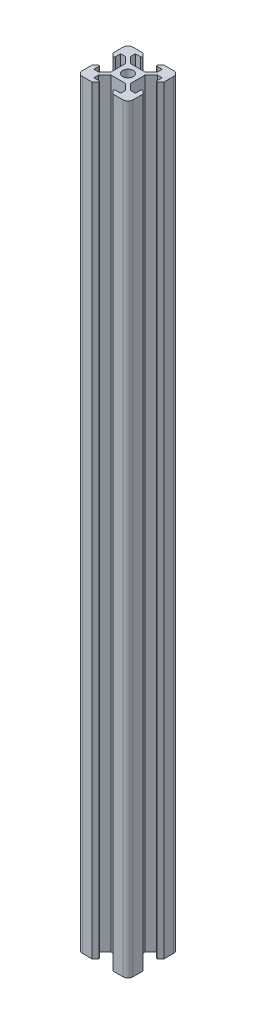
from build123d import *

# Parameters (mm, degrees)
CROQUIS1_R              = 2.1
SALIENTE_EXTRUIR2_DEPTH = 300


with BuildPart() as part:
    # Croquis1 → Saliente-Extruir2 (new body)
    with BuildSketch(Plane(origin=(0, 0, 0), x_dir=(1, 0, 0), z_dir=(0, 1, 0))):
        with BuildLine():
            Line((3.9, -2.84), (3.9, 2.84))
            Line((3.9, 2.84), (6.36, 5.3))
            Line((6.36, 5.3), (8.2, 5.3))
            Line((8.2, 5.3), (8.2, 3.34))
            ThreePointArc((8.2, 3.34), (8.346446609, 2.986446609), (8.7, 2.84))
            Line((8.7, 2.84), (10, 4.14))
            Line((10, 4.14), (10, 8))
            ThreePointArc((10, 8), (9.414213562, 9.414213562), (8, 10))
            Line((8, 10), (4.14, 10))
            Line((4.14, 10), (2.84, 8.7))
            ThreePointArc((2.84, 8.7), (2.986446609, 8.346446609), (3.34, 8.2))
            Line((3.34, 8.2), (5.3, 8.2))
            Line((5.3, 8.2), (5.3, 6.36))
            Line((5.3, 6.36), (2.84, 3.9))
            Line((2.84, 3.9), (-2.84, 3.9))
            Line((-2.84, 3.9), (-5.3, 6.36))
            Line((-5.3, 6.36), (-5.3, 8.2))
            Line((-5.3, 8.2), (-3.34, 8.2))
            ThreePointArc((-3.34, 8.2), (-2.986446609, 8.346446609), (-2.84, 8.7))
            Line((-2.84, 8.7), (-4.14, 10))
            Line((-4.14, 10), (-8, 10))
            ThreePointArc((-8, 10), (-9.414213562, 9.414213562), (-10, 8))
            Line((-10, 8), (-10, 4.14))
            Line((-10, 4.14), (-8.7, 2.84))
            ThreePointArc((-8.7, 2.84), (-8.346446609, 2.986446609), (-8.2, 3.34))
            Line((-8.2, 3.34), (-8.2, 5.3))
            Line((-8.2, 5.3), (-6.36, 5.3))
            Line((-6.36, 5.3), (-3.9, 2.84))
            Line((-3.9, 2.84), (-3.9, -2.84))
            Line((-3.9, -2.84), (-6.36, -5.3))
            Line((-6.36, -5.3), (-8.2, -5.3))
            Line((-8.2, -5.3), (-8.2, -3.34))
            ThreePointArc((-8.2, -3.34), (-8.346446609, -2.986446609), (-8.7, -2.84))
            Line((-8.7, -2.84), (-10, -4.14))
            Line((-10, -4.14), (-10, -8))
            ThreePointArc((-10, -8), (-9.414213562, -9.414213562), (-8, -10))
            Line((-8, -10), (-4.14, -10))
            Line((-4.14, -10), (-2.84, -8.7))
            ThreePointArc((-2.84, -8.7), (-2.986446609, -8.346446609), (-3.34, -8.2))
            Line((-3.34, -8.2), (-5.3, -8.2))
            Line((-5.3, -8.2), (-5.3, -6.36))
            Line((-5.3, -6.36), (-2.84, -3.9))
            Line((-2.84, -3.9), (2.84, -3.9))
            Line((2.84, -3.9), (5.3, -6.36))
            Line((5.3, -6.36), (5.3, -8.2))
            Line((5.3, -8.2), (3.34, -8.2))
            ThreePointArc((3.34, -8.2), (2.986446609, -8.346446609), (2.84, -8.7))
            Line((2.84, -8.7), (4.14, -10))
            Line((4.14, -10), (8, -10))
            ThreePointArc((8, -10), (9.414213562, -9.414213562), (10, -8))
            Line((10, -8), (10, -4.14))
            Line((10, -4.14), (8.7, -2.84))
            ThreePointArc((8.7, -2.84), (8.346446609, -2.986446609), (8.2, -3.34))
            Line((8.2, -3.34), (8.2, -5.3))
            Line((8.2, -5.3), (6.36, -5.3))
            Line((6.36, -5.3), (3.9, -2.84))
        make_face()
        Circle(CROQUIS1_R, mode=Mode.SUBTRACT)
    extrude(amount=SALIENTE_EXTRUIR2_DEPTH)


solid = part.part
